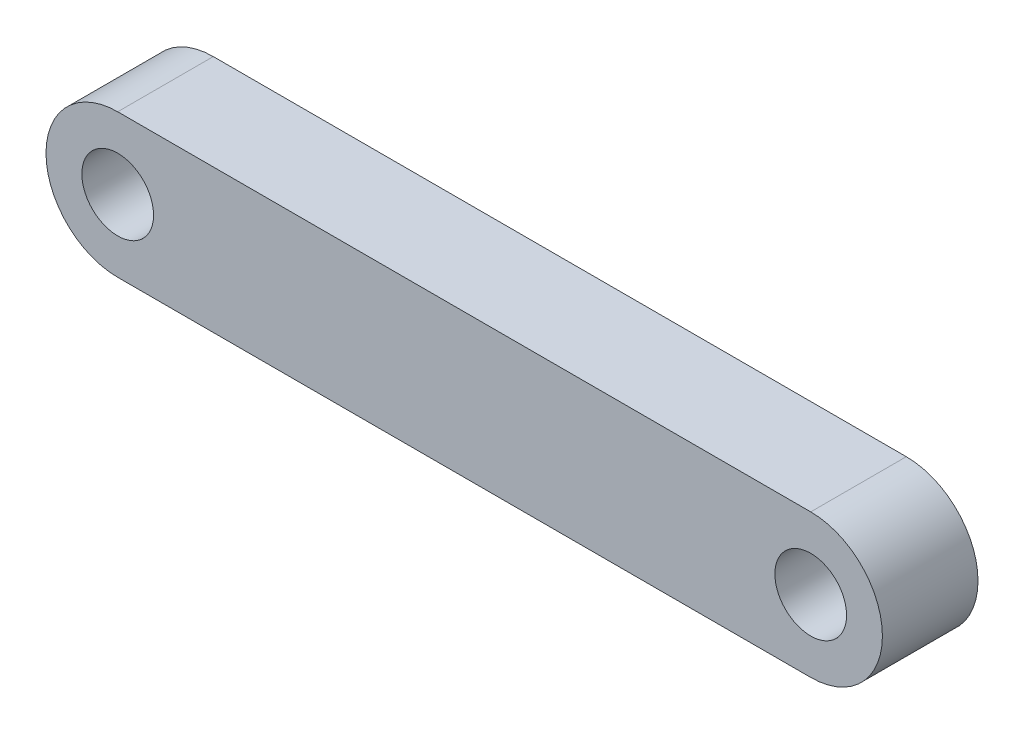
from build123d import *

# Parameters (mm, degrees)
SKETCH1_R           = 1.5
BOSS_EXTRUDE1_DEPTH = 4


with BuildPart() as part:
    # Sketch1 → Boss-Extrude1 (new body)
    with BuildSketch(Plane.XY):
        with BuildLine():
            Line((2.999999305, 5.999999755), (31.999999305, 5.999999755))
            ThreePointArc((31.999999305, 5.999999755), (34.999999305, 2.999999755), (31.999999305, -2.45e-07))
            Line((31.999999305, -2.45e-07), (2.999999305, -2.45e-07))
            ThreePointArc((2.999999305, -2.45e-07), (-6.95e-07, 2.999999755), (2.999999305, 5.999999755))
        make_face()
        with Locations((2.999999305, 2.999999755)):
            Circle(SKETCH1_R, mode=Mode.SUBTRACT)
        with Locations((31.999999305, 2.999999755)):
            Circle(SKETCH1_R, mode=Mode.SUBTRACT)
    extrude(amount=BOSS_EXTRUDE1_DEPTH)


solid = part.part
